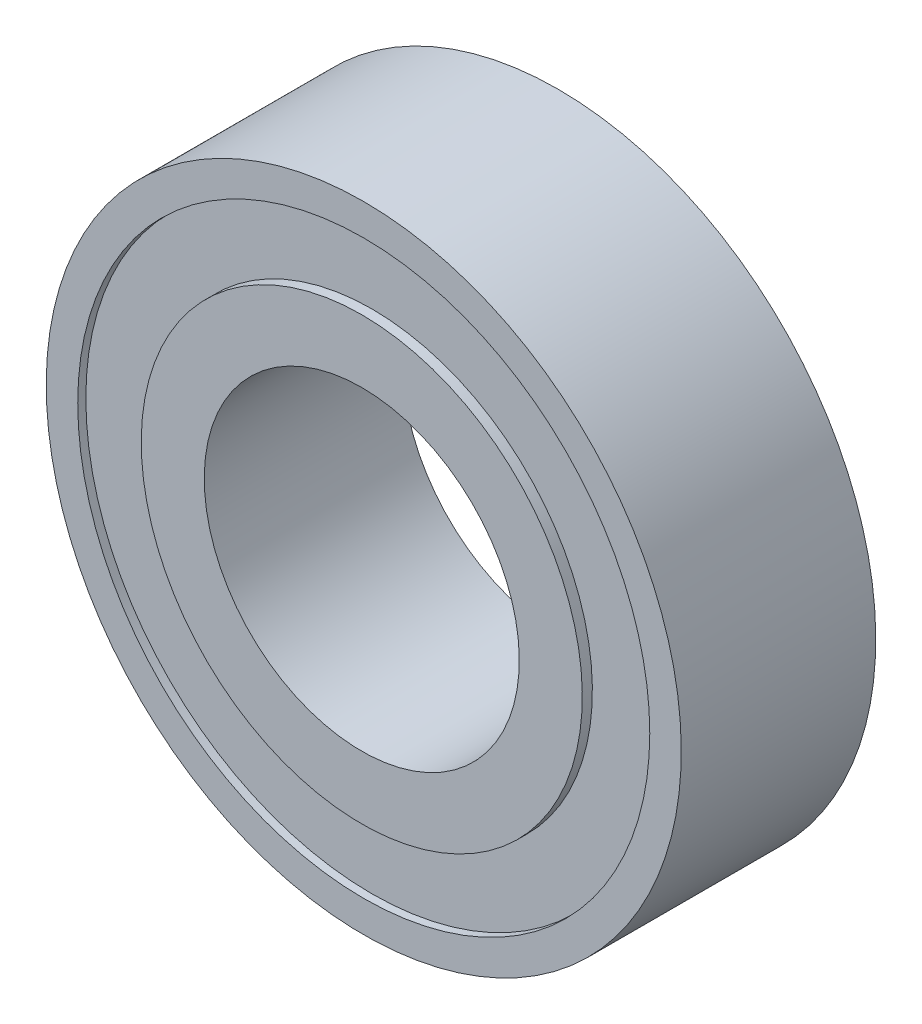
from build123d import *


with BuildPart() as part:
    # Sketch1 → Revolve1 (revolve)
    with BuildSketch(Plane(origin=(0, 0, 0), x_dir=(0, 0, -1), z_dir=(1, 0, 0))):
        Polygon((-5, 3.96875), (0, 3.96875), (0, 5.55625), (-0.254, 5.55625), (-0.254, 7.20625), (-0.05, 7.20625), (-0.05, 8), (-4.95, 8), (-4.95, 7.20625), (-4.746, 7.20625), (-4.746, 5.55625), (-5, 5.55625), align=None)
    revolve(axis=Axis((0, 0, 0), (0, 0, 1)))


solid = part.part
